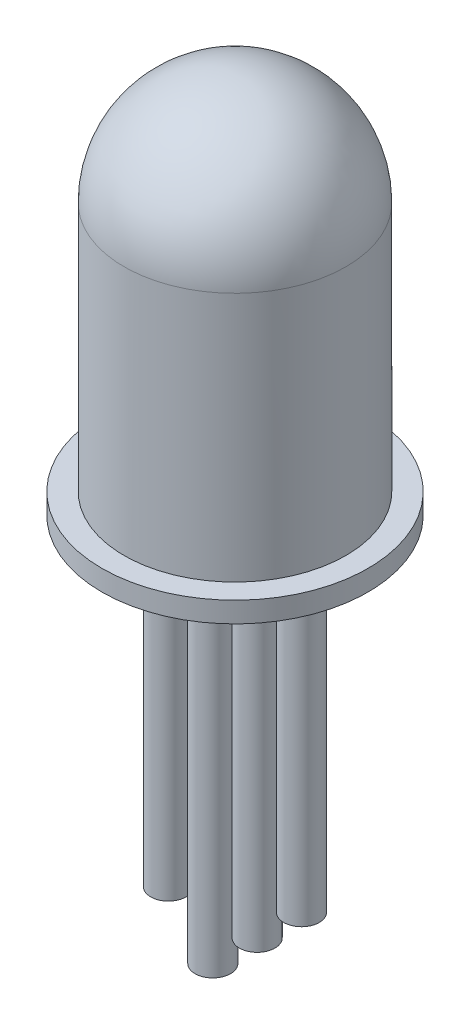
from build123d import *

# Parameters (mm, degrees)
ESBO_O1_W                = 2.5
ESBO_O1_H                = 0.463123709
ESBO_O1_W_2              = 0.5
ESBO_O2_R                = 0.4
RESSALTO_EXTRUS_O1_DEPTH = 7
ESBO_O3_R                = 0.4
RESSALTO_EXTRUS_O2_DEPTH = 1
ESBO_O4_R                = 0.4
RESSALTO_EXTRUS_O3_DEPTH = 2


with BuildPart() as part:
    # Esboço1 → Revolução1 (revolve)
    with BuildSketch(Plane.XY):
        with BuildLine():
            Line((0, 7.133898305), (0, 4.633898305))
            ThreePointArc((0, 4.633898305), (1.767766953, 5.366131352), (2.5, 7.133898305))
            Line((2.5, 7.133898305), (0, 7.133898305))
        make_face()
        with BuildLine():
            Line((0, 9.633898305), (0, 7.133898305))
            Line((0, 7.133898305), (2.5, 7.133898305))
            ThreePointArc((2.5, 7.133898305), (1.767766953, 8.901665258), (0, 9.633898305))
        make_face()
        with BuildLine():
            Line((0, 7.133898305), (0, 4.633898305))
            ThreePointArc((0, 4.633898305), (1.767766953, 5.366131352), (2.5, 7.133898305))
            Line((2.5, 7.133898305), (0, 7.133898305))
        make_face()
        with BuildLine():
            Line((0, 9.633898305), (0, 7.133898305))
            Line((0, 7.133898305), (2.5, 7.133898305))
            ThreePointArc((2.5, 7.133898305), (1.767766953, 8.901665258), (0, 9.633898305))
        make_face()
        with BuildLine():
            Line((0, 4.633898305), (0, 1.497022014))
            Line((0, 1.497022014), (2.5, 1.497022014))
            Line((2.5, 1.497022014), (2.5, 7.133898305))
            ThreePointArc((2.5, 7.133898305), (1.767766953, 5.366131352), (0, 4.633898305))
        make_face()
        with Locations((1.25, 1.26546016)):
            Rectangle(ESBO_O1_W, ESBO_O1_H)
        with Locations((2.75, 1.26546016)):
            Rectangle(ESBO_O1_W_2, ESBO_O1_H)
    revolve(axis=Axis((0, 1.033898305, 0), (0, 1, 0)))

    # Esboço2 → Ressalto-extrusão1 (add)
    with BuildSketch(Plane.XZ.offset(-1.033898305)):
        with Locations((-1.5, 0)):
            Circle(ESBO_O2_R)
        with Locations((-0.5, 0)):
            Circle(ESBO_O2_R)
        with Locations((0.5, 0)):
            Circle(ESBO_O2_R)
        with Locations((1.5, 0)):
            Circle(ESBO_O2_R)
    extrude(amount=RESSALTO_EXTRUS_O1_DEPTH)

    # Esboço3 → Ressalto-extrusão2 (add)
    with BuildSketch(Plane.XZ.offset(5.966101695)):
        with Locations((0.5, 0)):
            Circle(ESBO_O3_R)
        with Locations((-1.5, 0)):
            Circle(ESBO_O3_R)
    extrude(amount=RESSALTO_EXTRUS_O2_DEPTH)

    # Esboço4 → Ressalto-extrusão3 (add)
    with BuildSketch(Plane.XZ.offset(5.966101695)):
        with Locations((-0.5, 0)):
            Circle(ESBO_O4_R)
    extrude(amount=RESSALTO_EXTRUS_O3_DEPTH)


solid = part.part
